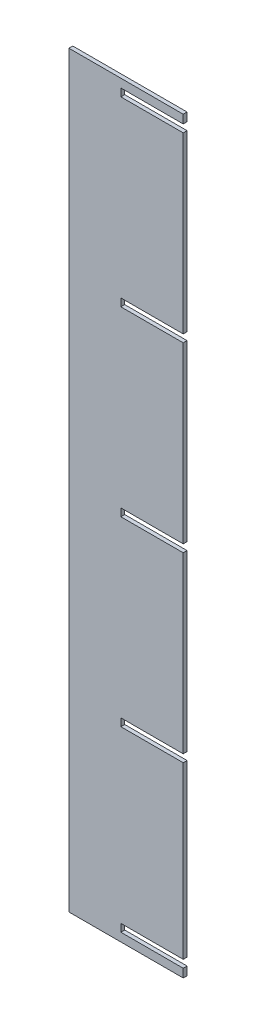
from build123d import *

# Parameters (mm, degrees)
BOSS_EXTRUDE1_DEPTH = 9.398


with BuildPart() as part:
    # Sketch1 → Boss-Extrude1 (new body)
    with BuildSketch(Plane.XY):
        Polygon((26087.861998544, 8828.751571885), (26087.861998544, 6999.951571885), (26367.261998544, 6999.951571885), (26367.261998544, 7020.652571885), (26214.861998544, 7020.652571885), (26214.861998544, 7039.448571885), (26367.261998544, 7039.448571885), (26367.261998544, 7455.754571885), (26214.861998544, 7455.754571885), (26214.861998544, 7474.550571885), (26367.261998544, 7474.550571885), (26367.261998544, 7900.254571885), (26214.861998544, 7900.254571885), (26214.861998544, 7919.050571885), (26367.261998544, 7919.050571885), (26367.261998544, 8344.754571885), (26214.861998544, 8344.754571885), (26214.861998544, 8363.550571885), (26367.261998544, 8363.550571885), (26367.261998544, 8789.254571885), (26214.861998544, 8789.254571885), (26214.861998544, 8808.050571885), (26367.261998544, 8808.050571885), (26367.261998544, 8828.751571885), align=None)
    extrude(amount=BOSS_EXTRUDE1_DEPTH)


solid = part.part
